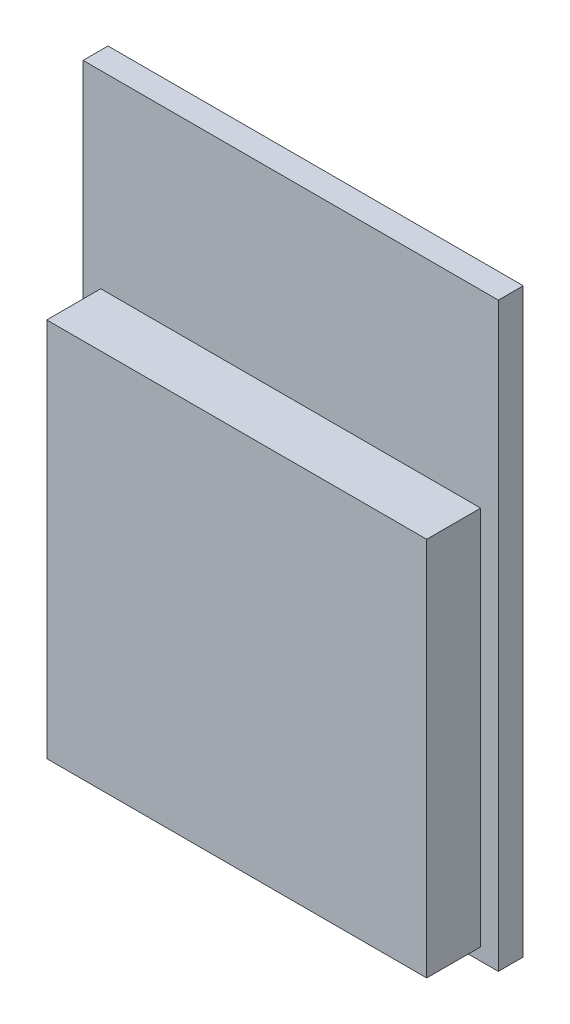
from build123d import *

# Parameters (mm, degrees)
SKETCH1_W           = 10
SKETCH1_H           = 14
BOSS_EXTRUDE1_DEPTH = 0.6
SKETCH2_W           = 9.15
SKETCH2_H           = 9.15
BOSS_EXTRUDE2_DEPTH = 1.3


with BuildPart() as part:
    # Sketch1 → Boss-Extrude1 (new body)
    with BuildSketch(Plane.XY):
        Rectangle(SKETCH1_W, SKETCH1_H)
    extrude(amount=BOSS_EXTRUDE1_DEPTH)

    # Sketch2 → Boss-Extrude2 (add)
    with BuildSketch(Plane.XY.offset(0.6)):
        with Locations((0, -2.125)):
            Rectangle(SKETCH2_W, SKETCH2_H)
    extrude(amount=BOSS_EXTRUDE2_DEPTH)


solid = part.part
